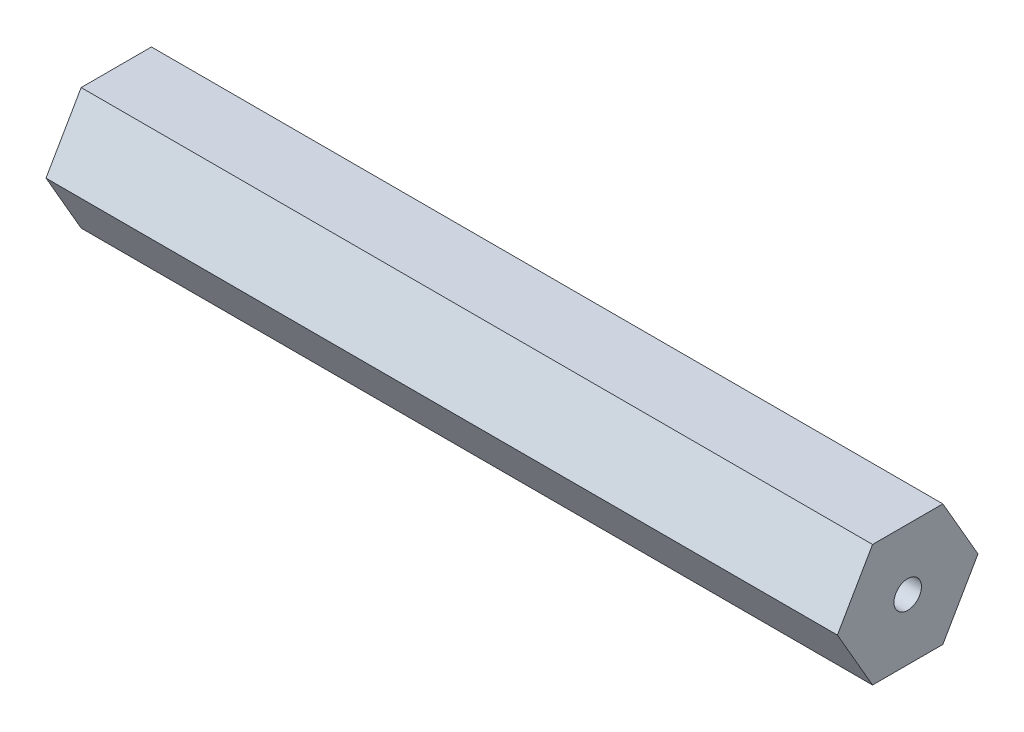
from build123d import *

# Parameters (mm, degrees)
SKETCH1_R           = 1.431738184
BOSS_EXTRUDE1_DEPTH = 82.55


with BuildPart() as part:
    # Sketch1 → Boss-Extrude1 (new body)
    with BuildSketch(Plane(origin=(0, 0, 0), x_dir=(0, 0, -1), z_dir=(1, 0, 0))):
        Polygon((3.666174209, -6.35), (7.332348419, 0), (3.666174209, 6.35), (-3.666174209, 6.35), (-7.332348419, 0), (-3.666174209, -6.35), align=None)
        Circle(SKETCH1_R, mode=Mode.SUBTRACT)
    extrude(amount=BOSS_EXTRUDE1_DEPTH)


solid = part.part
